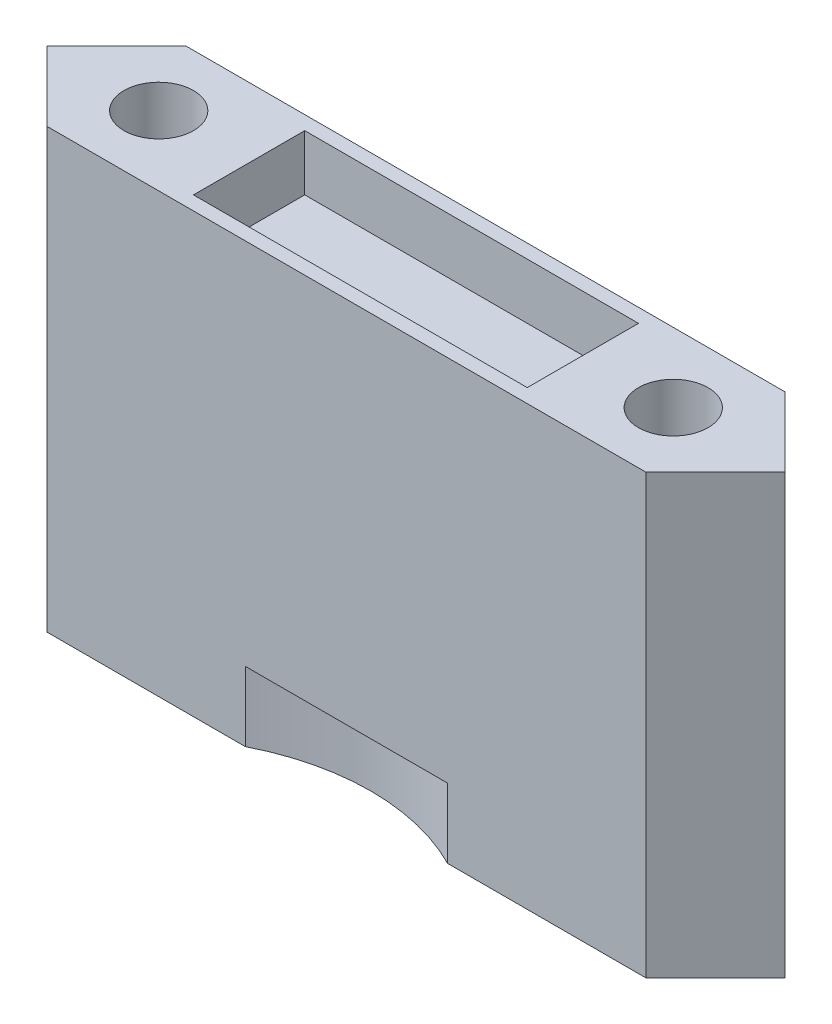
from build123d import *

# Parameters (mm, degrees)
SKETCH1_R           = 3.175
BOSS_EXTRUDE1_DEPTH = 40
SKETCH2_W           = 30.48
SKETCH2_H           = 10.16
CUT_EXTRUDE1_DEPTH  = 5.08
SKETCH3_R           = 20.32
CUT_EXTRUDE2_DEPTH  = 6.35


with BuildPart() as part:
    # Sketch1 → Boss-Extrude1 (new body)
    with BuildSketch(Plane(origin=(0, 0, 0), x_dir=(1, 0, 0), z_dir=(0, 1, 0))):
        Polygon((-27.358849143, 6.35), (-33.708849143, 0), (-27.358849143, -6.35), (27.358849143, -6.35), (33.708849143, 0), (27.358849143, 6.35), align=None)
        with Locations((-23.495, 0)):
            Circle(SKETCH1_R, mode=Mode.SUBTRACT)
        with Locations((23.495, 0)):
            Circle(SKETCH1_R, mode=Mode.SUBTRACT)
    extrude(amount=BOSS_EXTRUDE1_DEPTH)

    # Sketch2 → Cut-Extrude1 (cut)
    with BuildSketch(Plane(origin=(0, 40, 0), x_dir=(1, 0, 0), z_dir=(0, 1, 0))):
        Rectangle(SKETCH2_W, SKETCH2_H)
    extrude(amount=-CUT_EXTRUDE1_DEPTH, mode=Mode.SUBTRACT)

    # Sketch3 → Cut-Extrude2 (cut)
    with BuildSketch(Plane(origin=(0, 0, 0), x_dir=(-1, 0, 0), z_dir=(0, -1, 0))):
        with Locations((0, -24.45005636)):
            Circle(SKETCH3_R)
    extrude(amount=-CUT_EXTRUDE2_DEPTH, mode=Mode.SUBTRACT)


solid = part.part
